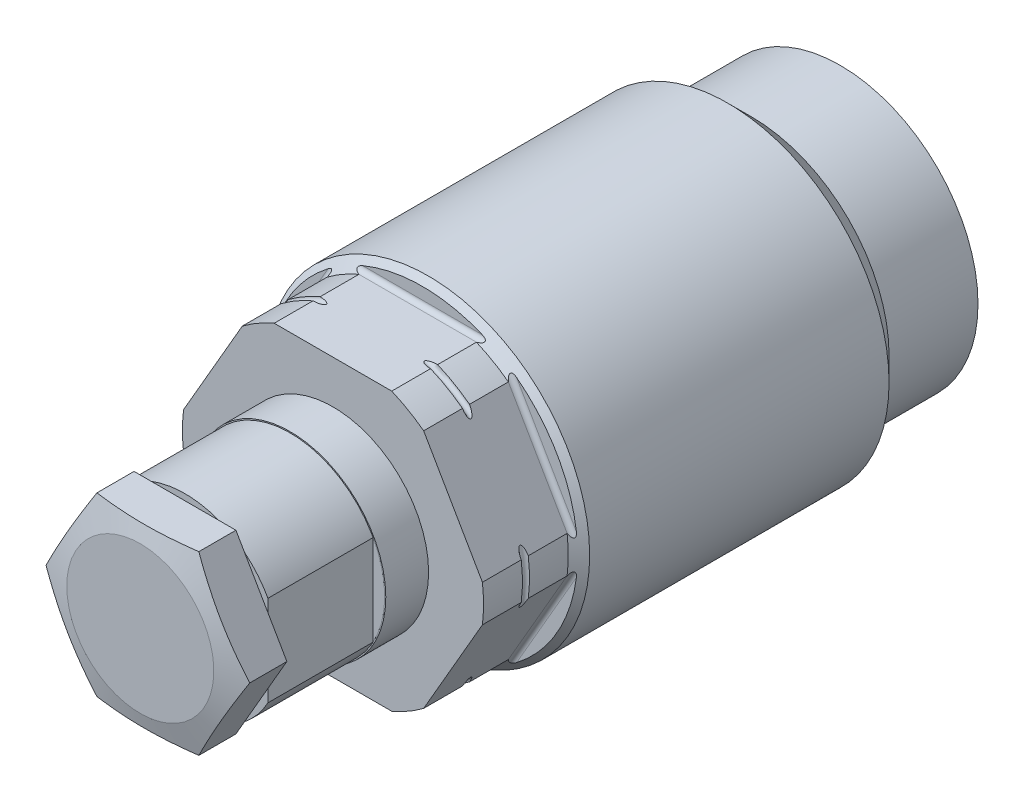
from build123d import *

# Parameters (mm, degrees)
CUT_EXTRUDE1_DEPTH      = 18.4117
CIRPATTERN1_COUNT       = 6
SKETCH3_W               = 15.9766
SKETCH3_H               = 10.3251
SKETCH4_R               = 5.9944
CUT_EXTRUDE2_DEPTH      = 7.874
SKETCH10_W              = 1.3716
SKETCH10_H              = 11.3538
CUT_EXTRUDE3_DEPTH      = 18.4117001
CUT_EXTRUDE3_DEPTH_BACK = 18.4117001
EXTRUDE2_DEPTH          = 4.826
SKETCH13_W              = 11.354
SKETCH13_H              = 0.1251


with BuildPart() as part:
    # Sketch1 → Revolve1 (revolve)
    with BuildSketch(Plane(origin=(0, 0, 0), x_dir=(0, 0, -1), z_dir=(1, 0, 0)), mode=Mode.PRIVATE) as revolve1_sk:
        Polygon((0, 0), (0, 14.8717), (-9.6012, 14.8717), (-12.1412, 17.4117), (-44.4627, 17.4117), (-45.6184, 16.256), (-54.7624, 16.256), (-54.7624, 0), align=None)
    revolve(revolve1_sk.sketch.rotate(Axis((0, 0, 0), (0, 0, -1)), 90), axis=Axis((0, 0, 0), (0, 0, -1)))  # turned: the seam where the file's is

    # Sketch2 → Cut-Extrude1 (cut, symmetric)
    with BuildSketch(Plane(origin=(0, 0, 0), x_dir=(0, 0, -1), z_dir=(1, 0, 0))):
        with BuildLine():
            Line((-54.7624, 14.96695), (-45.6184, 14.96695))
            ThreePointArc((-45.6184, 14.96695), (-45.259189755, 15.115739755), (-45.1104, 15.47495))
            Line((-45.1104, 15.47495), (-45.1104, 18.14195))
            Line((-45.1104, 18.14195), (-54.7624, 18.14195))
            Line((-54.7624, 18.14195), (-54.7624, 14.96695))
        make_face()
    cut_extrude1 = extrude(amount=CUT_EXTRUDE1_DEPTH, both=True, mode=Mode.SUBTRACT)

    # CirPattern1: Cut-Extrude1 ×6 about axis
    cirpattern1_axis = Axis((0, 0, 0), (0, 0, 1))
    for i in range(1, CIRPATTERN1_COUNT):
        add(cut_extrude1.rotate(cirpattern1_axis, i * 360 / CIRPATTERN1_COUNT), mode=Mode.SUBTRACT)

    # Sketch3 → Revolve2 (revolve)
    with BuildSketch(Plane(origin=(0, 0, 0), x_dir=(0, 0, -1), z_dir=(1, 0, 0)), mode=Mode.PRIVATE) as revolve2_sk:
        with Locations((-62.7507, 5.16255)):
            Rectangle(SKETCH3_W, SKETCH3_H)
    revolve(revolve2_sk.sketch.rotate(Axis((0, 0, 0), (0, 0, 1)), 270), axis=Axis((0, 0, 0), (0, 0, 1)))  # turned: the seam where the file's is

    # Sketch4 → Cut-Extrude2 (cut)
    with BuildSketch(Plane.XY.offset(70.739)):
        Circle(SKETCH4_R)
    extrude(amount=-CUT_EXTRUDE2_DEPTH, mode=Mode.SUBTRACT)

    # Sketch5 → Cut-Revolve1 (revolve, cut)
    with BuildSketch(Plane(origin=(0, 0, 0), x_dir=(0, 0, -1), z_dir=(1, 0, 0)), mode=Mode.PRIVATE) as cut_revolve1_sk:
        with BuildLine():
            Line((-50.5714, 19.431), (-50.5714, 16.256))
            ThreePointArc((-50.5714, 16.256), (-50.1904, 15.875), (-49.8094, 16.256))
            Line((-49.8094, 16.256), (-49.8094, 19.431))
            Line((-49.8094, 19.431), (-50.5714, 19.431))
        make_face()
    revolve(cut_revolve1_sk.sketch.rotate(Axis((0, 0, 0), (0, 0, 1)), 270), axis=Axis((0, 0, 0), (0, 0, 1)), mode=Mode.SUBTRACT)  # turned: the seam where the file's is

    # Sketch10 → Cut-Extrude3 (cut, two sides)
    with BuildSketch(Plane(origin=(0, 0, 0), x_dir=(1, 0, 0), z_dir=(0, 1, 0))) as cut_extrude3_sk:
        with Locations((9.6393, -65.0621)):
            Rectangle(SKETCH10_W, SKETCH10_H)
        with Locations((-9.6393, -65.0621)):
            Rectangle(SKETCH10_W, SKETCH10_H)
    extrude(amount=CUT_EXTRUDE3_DEPTH, mode=Mode.SUBTRACT)
    extrude(cut_extrude3_sk.sketch, amount=-CUT_EXTRUDE3_DEPTH_BACK, mode=Mode.SUBTRACT)

    # Sketch11 → Extrude2 (add)
    with BuildSketch(Plane.XY.offset(70.739)):
        Polygon((5.499261314, 9.525), (-5.499261314, 9.525), (-10.998522628, 0), (-5.499261314, -9.525), (5.499261314, -9.525), (10.998522628, 0), align=None)
    extrude(amount=EXTRUDE2_DEPTH)

    # Sketch12 → Cut-Revolve3 (revolve, cut)
    with BuildSketch(Plane(origin=(0, 0, 0), x_dir=(1, 0, 0), z_dir=(0, 1, 0)), mode=Mode.PRIVATE) as cut_revolve3_sk:
        Polygon((-10.998522628, -74.744801459), (-10.998522628, -75.565), (-7.9375, -75.565), align=None)
    revolve(cut_revolve3_sk.sketch.rotate(Axis((0, 0, 0), (0, 0, 1)), 180), axis=Axis((0, 0, 0), (0, 0, 1)), mode=Mode.SUBTRACT)  # turned: the seam where the file's is

    # Sketch13 → Cut-Revolve4 (revolve, cut)
    with BuildSketch(Plane(origin=(0, 0, 0), x_dir=(0, 0, -1), z_dir=(1, 0, 0)), mode=Mode.PRIVATE) as cut_revolve4_sk:
        with Locations((-65.062, 10.26255)):
            Rectangle(SKETCH13_W, SKETCH13_H)
    revolve(cut_revolve4_sk.sketch.rotate(Axis((0, 0, 0), (0, 0, 1)), 97.029074864), axis=Axis((0, 0, 0), (0, 0, 1)), mode=Mode.SUBTRACT)  # turned: the seam where the file's is


solid = part.part
